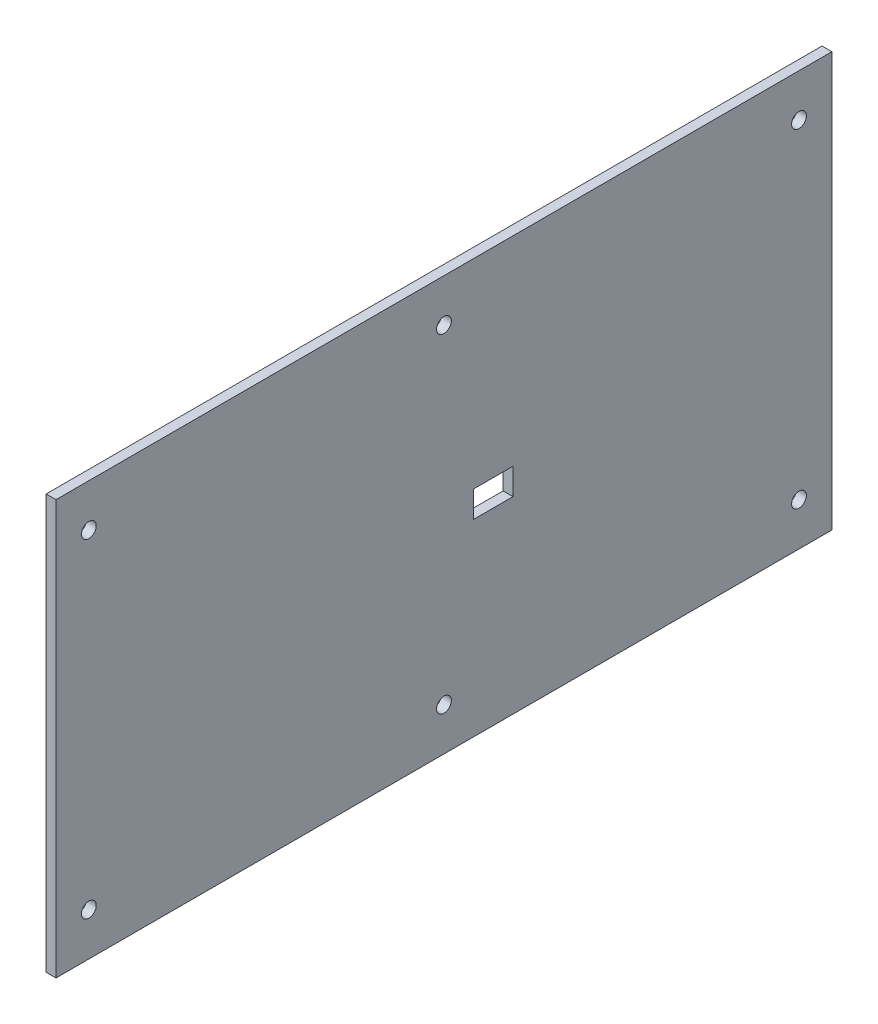
from build123d import *

# Parameters (mm, degrees)
SKETCH_1_W          = 236
SKETCH_1_H          = 126
EXTRUDE_1_DEPTH     = 3
SKETCH_2_R          = 2.25
CUT_EXTRUDE_1_DEPTH = 4
SKETCH_3_W          = 12
SKETCH_3_H          = 8
CUT_EXTRUDE_2_DEPTH = 4


with BuildPart() as part:
    # Эскиз1 → Бобышка-Вытянуть1 (new body)
    with BuildSketch(Plane.ZY.offset(240)):
        with Locations((118, 60)):
            Rectangle(SKETCH_1_W, SKETCH_1_H)
    extrude(amount=EXTRUDE_1_DEPTH)

    # Эскиз2 → Вырез-Вытянуть1 (cut, through all)
    with BuildSketch(Plane.ZY.offset(243)):
        with Locations((226, 110)):
            Circle(SKETCH_2_R)
        with Locations((118, 110)):
            Circle(SKETCH_2_R)
        with Locations((10, 110)):
            Circle(SKETCH_2_R)
        with Locations((226, 10)):
            Circle(SKETCH_2_R)
        with Locations((118, 10)):
            Circle(SKETCH_2_R)
        with Locations((10, 10)):
            Circle(SKETCH_2_R)
    extrude(amount=-CUT_EXTRUDE_1_DEPTH, mode=Mode.SUBTRACT)

    # Эскиз3 → Вырез-Вытянуть2 (cut, through all)
    with BuildSketch(Plane(origin=(-240, 0, 0), x_dir=(0, 0, -1), z_dir=(1, 0, 0))):
        with Locations((-103, 58.3)):
            Rectangle(SKETCH_3_W, SKETCH_3_H)
    extrude(amount=-CUT_EXTRUDE_2_DEPTH, mode=Mode.SUBTRACT)


solid = part.part
